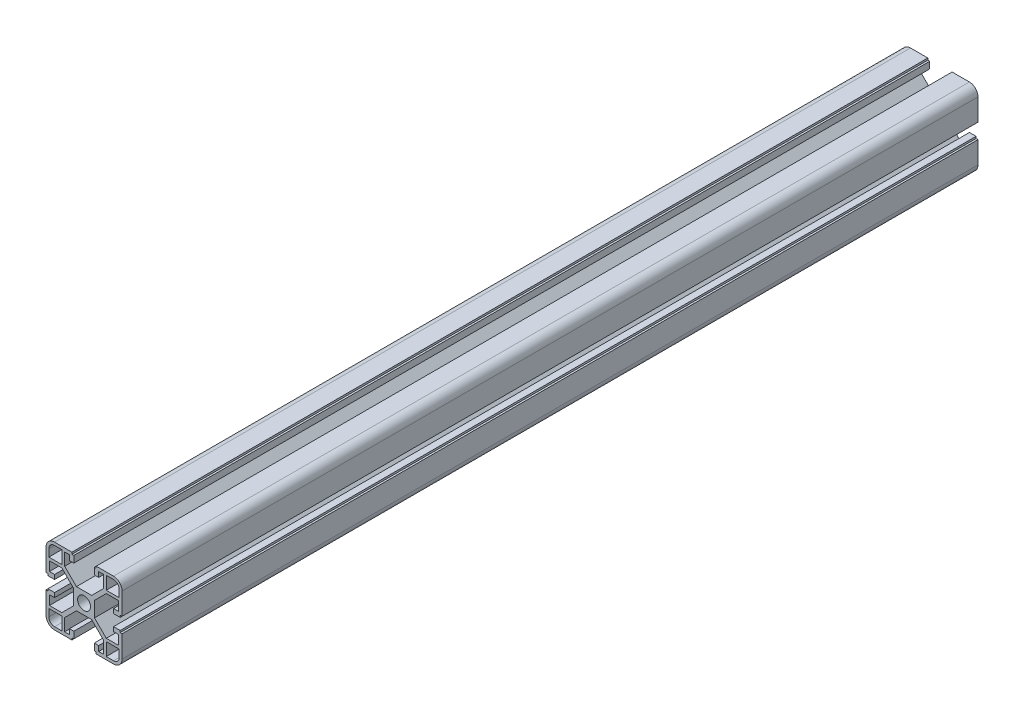
from build123d import *

# Parameters (mm, degrees)
BOSS_EXTRUDE1_DEPTH  = 450
MIRROR3_COPY_1_DEPTH = 450
MIRROR3_COPY_2_DEPTH = 450


with BuildPart() as part:
    # Sketch1 → Boss-Extrude1 (new body)
    with BuildSketch(Plane.XY):
        with BuildLine():
            Line((3.4, 0), (5.5, 0))
            Line((5.5, 0), (5.5, 4))
            Line((5.5, 4), (11.69, 10.19))
            Line((11.69, 10.19), (18.2, 10.19))
            Line((18.2, 10.19), (18.2, 5.265595036))
            Line((18.2, 5.265595036), (15.5, 5.265595036))
            Line((15.5, 5.265595036), (15.5, 2.965595036))
            Line((15.5, 2.965595036), (19, 2.965595036))
            Line((19, 2.965595036), (19, 3.965595036))
            Line((19, 3.965595036), (20, 3.965595036))
            Line((20, 3.965595036), (20, 15.5))
            ThreePointArc((20, 15.5), (18.681980515, 18.681980515), (15.5, 20))
            Line((15.5, 20), (6.385304712, 20))
            Line((6.385304712, 20), (6.385304712, 19))
            Line((6.385304712, 19), (5.385304712, 19))
            Line((5.385304712, 19), (5.385304712, 15.5))
            Line((5.385304712, 15.5), (7.685304712, 15.5))
            Line((7.685304712, 15.5), (7.685304712, 18.2))
            Line((7.685304712, 18.2), (10.19, 18.2))
            Line((10.19, 18.2), (10.19, 11.69))
            Line((10.19, 11.69), (4, 5.5))
            Line((4, 5.5), (0, 5.5))
            Line((0, 5.5), (0, 3.4))
            ThreePointArc((0, 3.4), (2.404163056, 2.404163056), (3.4, 0))
        make_face()
        with BuildLine():
            Line((18.5, 11.69), (18.5, 15.5))
            ThreePointArc((18.5, 15.5), (17.621320344, 17.621320344), (15.5, 18.5))
            Line((15.5, 18.5), (11.69, 18.5))
            Line((11.69, 18.5), (11.69, 11.69))
            Line((11.69, 11.69), (18.5, 11.69))
        make_face(mode=Mode.SUBTRACT)
    boss_extrude1 = extrude(amount=BOSS_EXTRUDE1_DEPTH)

    # Mirror1: Boss-Extrude1 across plane
    add(boss_extrude1.mirror(Plane.ZX))

    # Mirror2: Boss-Extrude1 across plane
    add(boss_extrude1.mirror(Plane(origin=(0, 0, 0), x_dir=(0, 0, 1), z_dir=(1, 0, 0))))

    # Mirror3 copy 1 sketch → Mirror3 copy 1 (add)
    with BuildSketch(Plane(origin=(0, 0, 0), x_dir=(-1, 0, 0), z_dir=(0, 0, 1))):
        with BuildLine():
            Line((3.4, 0), (5.5, 0))
            Line((5.5, 0), (5.5, 4))
            Line((5.5, 4), (11.69, 10.19))
            Line((11.69, 10.19), (18.2, 10.19))
            Line((18.2, 10.19), (18.2, 5.265595036))
            Line((18.2, 5.265595036), (15.5, 5.265595036))
            Line((15.5, 5.265595036), (15.5, 2.965595036))
            Line((15.5, 2.965595036), (19, 2.965595036))
            Line((19, 2.965595036), (19, 3.965595036))
            Line((19, 3.965595036), (20, 3.965595036))
            Line((20, 3.965595036), (20, 15.5))
            ThreePointArc((20, 15.5), (18.681980515, 18.681980515), (15.5, 20))
            Line((15.5, 20), (6.385304712, 20))
            Line((6.385304712, 20), (6.385304712, 19))
            Line((6.385304712, 19), (5.385304712, 19))
            Line((5.385304712, 19), (5.385304712, 15.5))
            Line((5.385304712, 15.5), (7.685304712, 15.5))
            Line((7.685304712, 15.5), (7.685304712, 18.2))
            Line((7.685304712, 18.2), (10.19, 18.2))
            Line((10.19, 18.2), (10.19, 11.69))
            Line((10.19, 11.69), (4, 5.5))
            Line((4, 5.5), (0, 5.5))
            Line((0, 5.5), (0, 3.4))
            ThreePointArc((0, 3.4), (2.404163056, 2.404163056), (3.4, 0))
        make_face()
        with BuildLine():
            Line((18.5, 11.69), (18.5, 15.5))
            ThreePointArc((18.5, 15.5), (17.621320344, 17.621320344), (15.5, 18.5))
            Line((15.5, 18.5), (11.69, 18.5))
            Line((11.69, 18.5), (11.69, 11.69))
            Line((11.69, 11.69), (18.5, 11.69))
        make_face(mode=Mode.SUBTRACT)
    extrude(amount=MIRROR3_COPY_1_DEPTH)

    # Mirror3 copy 2 sketch → Mirror3 copy 2 (add)
    with BuildSketch(Plane.XY):
        with BuildLine():
            Line((3.4, 0), (5.5, 0))
            Line((5.5, 0), (5.5, -4))
            Line((5.5, -4), (11.69, -10.19))
            Line((11.69, -10.19), (18.2, -10.19))
            Line((18.2, -10.19), (18.2, -5.265595036))
            Line((18.2, -5.265595036), (15.5, -5.265595036))
            Line((15.5, -5.265595036), (15.5, -2.965595036))
            Line((15.5, -2.965595036), (19, -2.965595036))
            Line((19, -2.965595036), (19, -3.965595036))
            Line((19, -3.965595036), (20, -3.965595036))
            Line((20, -3.965595036), (20, -15.5))
            ThreePointArc((20, -15.5), (18.681980515, -18.681980515), (15.5, -20))
            Line((15.5, -20), (6.385304712, -20))
            Line((6.385304712, -20), (6.385304712, -19))
            Line((6.385304712, -19), (5.385304712, -19))
            Line((5.385304712, -19), (5.385304712, -15.5))
            Line((5.385304712, -15.5), (7.685304712, -15.5))
            Line((7.685304712, -15.5), (7.685304712, -18.2))
            Line((7.685304712, -18.2), (10.19, -18.2))
            Line((10.19, -18.2), (10.19, -11.69))
            Line((10.19, -11.69), (4, -5.5))
            Line((4, -5.5), (0, -5.5))
            Line((0, -5.5), (0, -3.4))
            ThreePointArc((0, -3.4), (2.404163056, -2.404163056), (3.4, 0))
        make_face()
        with BuildLine():
            Line((18.5, -11.69), (18.5, -15.5))
            ThreePointArc((18.5, -15.5), (17.621320344, -17.621320344), (15.5, -18.5))
            Line((15.5, -18.5), (11.69, -18.5))
            Line((11.69, -18.5), (11.69, -11.69))
            Line((11.69, -11.69), (18.5, -11.69))
        make_face(mode=Mode.SUBTRACT)
    extrude(amount=MIRROR3_COPY_2_DEPTH)


solid = part.part
